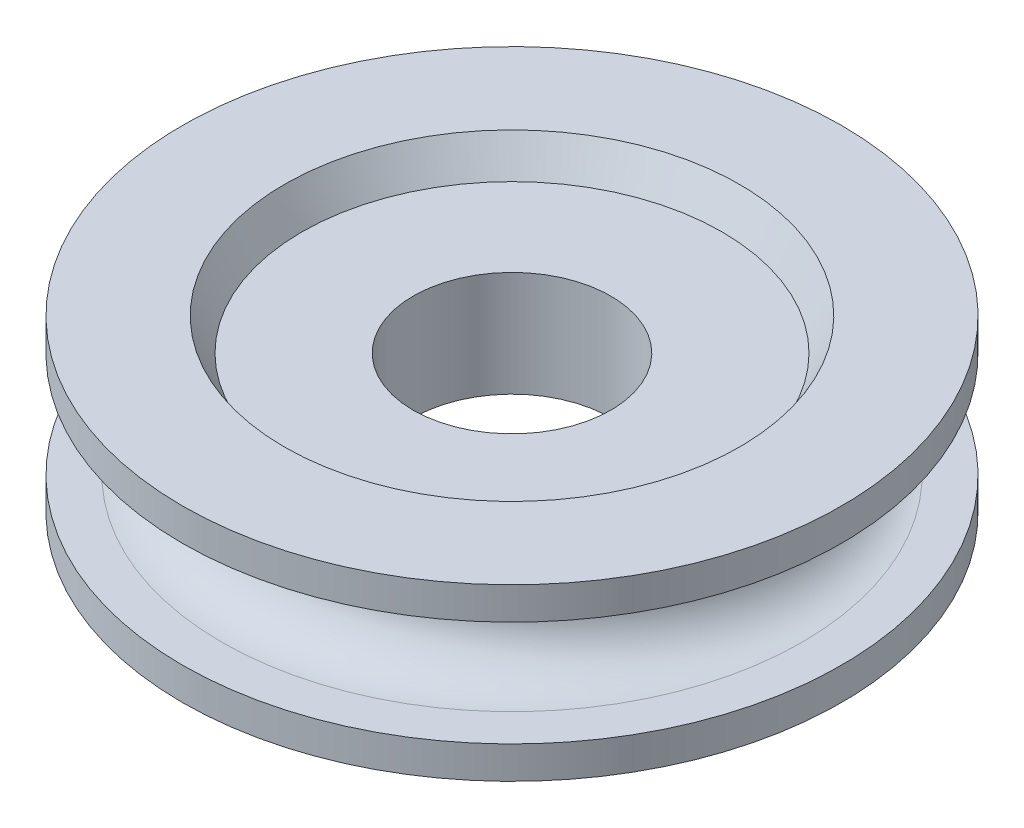
from build123d import *


with BuildPart() as part:
    # Эскиз1 → Повернуть1 (revolve)
    with BuildSketch(Plane.XY):
        with BuildLine():
            Line((7.5, 4), (7.5, -4))
            Line((7.5, -4), (15.93289357, -4))
            Line((15.93289357, -4), (17.26104157, -6.459147259))
            Line((17.26104157, -6.459147259), (25, -6.459147259))
            Line((25, -6.459147259), (25, -4))
            Line((25, -4), (22, -4))
            ThreePointArc((22, -4), (18, 0), (22, 4))
            Line((22, 4), (25, 4))
            Line((25, 4), (25, 6.459147259))
            Line((25, 6.459147259), (17.26104157, 6.459147259))
            Line((17.26104157, 6.459147259), (15.93289357, 4))
            Line((15.93289357, 4), (7.5, 4))
        make_face()
    revolve(axis=Axis((0, 40.932480583, 0), (0, -1, 0)))


solid = part.part
